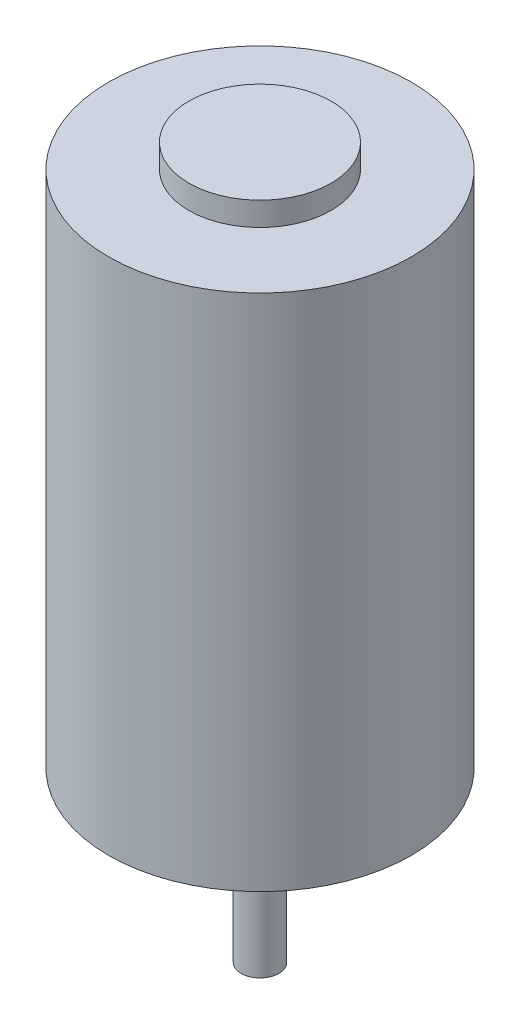
from build123d import *

# Parameters (mm, degrees)
SKETCH1_R           = 32.004
BOSS_EXTRUDE1_DEPTH = 114.6048
SKETCH2_R           = 32.004
SKETCH2_R_2         = 15.0368
CUT_EXTRUDE1_DEPTH  = 5.0038
SKETCH3_R           = 2.0193
CUT_EXTRUDE2_DEPTH  = 13.6144
SKETCH4_R           = 9.525
BOSS_EXTRUDE2_DEPTH = 3.9878
SKETCH6_R           = 4.0005
BOSS_EXTRUDE3_DEPTH = 35.6108


with BuildPart() as part:
    # Sketch1 → Boss-Extrude1 (new body)
    with BuildSketch(Plane(origin=(0, 0, 0), x_dir=(1, 0, 0), z_dir=(0, 1, 0))):
        Circle(SKETCH1_R)
    extrude(amount=BOSS_EXTRUDE1_DEPTH)

    # Sketch2 → Cut-Extrude1 (cut)
    with BuildSketch(Plane(origin=(0, 114.6048, 0), x_dir=(1, 0, 0), z_dir=(0, 1, 0))):
        Circle(SKETCH2_R)
        Circle(SKETCH2_R_2, mode=Mode.SUBTRACT)
    extrude(amount=-CUT_EXTRUDE1_DEPTH, mode=Mode.SUBTRACT)

    # Sketch3 → Cut-Extrude2 (cut)
    with BuildSketch(Plane(origin=(0, 0, 0), x_dir=(-1, 0, 0), z_dir=(0, -1, 0))):
        with Locations((0, -25.4)):
            Circle(SKETCH3_R)
        with Locations((0, 25.4)):
            Circle(SKETCH3_R)
    extrude(amount=-CUT_EXTRUDE2_DEPTH, mode=Mode.SUBTRACT)

    # Sketch4 → Boss-Extrude2 (add)
    with BuildSketch(Plane.XZ):
        Circle(SKETCH4_R)
    extrude(amount=BOSS_EXTRUDE2_DEPTH)

    # Sketch6 → Boss-Extrude3 (add)
    with BuildSketch(Plane(origin=(0, 0, 0), x_dir=(-1, 0, 0), z_dir=(0, -1, 0))):
        Circle(SKETCH6_R)
    extrude(amount=BOSS_EXTRUDE3_DEPTH)


solid = part.part
